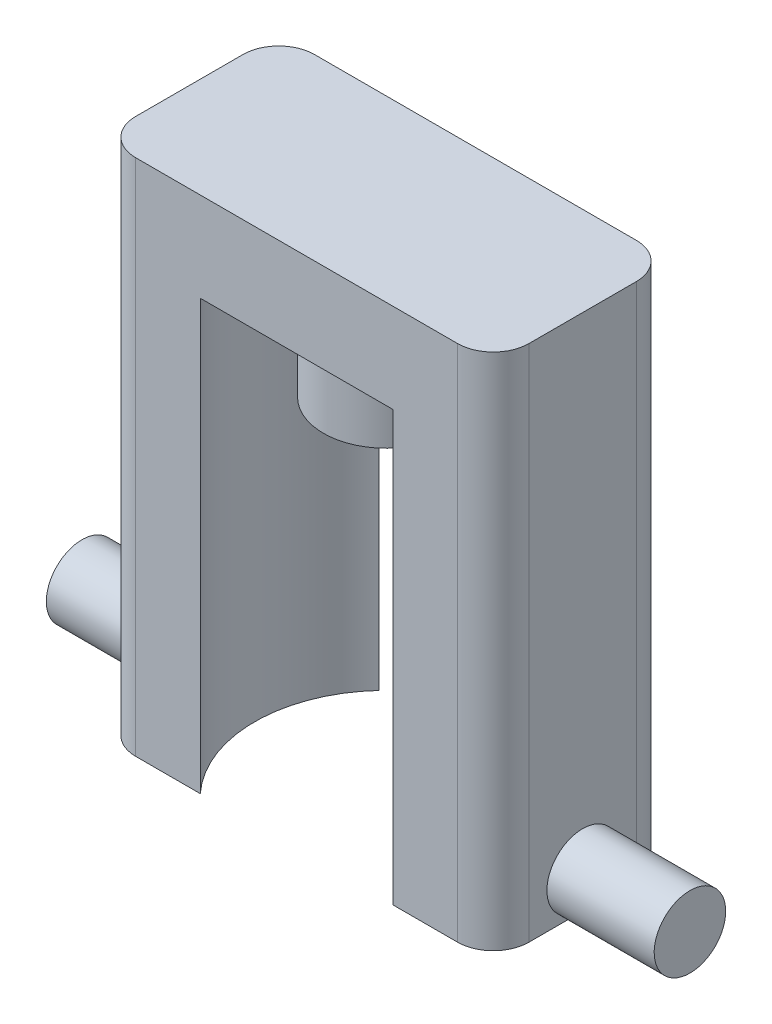
from build123d import *

# Parameters (mm, degrees)
SKETCH1_W           = 27.94
SKETCH1_H           = 12.7
BOSS_EXTRUDE1_DEPTH = 6.35
SKETCH2_R           = 4.445
BOSS_EXTRUDE2_DEPTH = 5.842
BOSS_EXTRUDE3_DEPTH = 30.48
SKETCH4_R           = 2.54
BOSS_EXTRUDE4_DEPTH = 7.62
SKETCH5_R           = 2.54
BOSS_EXTRUDE5_DEPTH = 7.62
FILLET1_R           = 2.54


with BuildPart() as part:
    # Sketch1 → Boss-Extrude1 (new body)
    with BuildSketch(Plane(origin=(0, 0, 0), x_dir=(1, 0, 0), z_dir=(0, 1, 0))):
        Rectangle(SKETCH1_W, SKETCH1_H)
    extrude(amount=BOSS_EXTRUDE1_DEPTH)

    # Sketch2 → Boss-Extrude2 (add)
    with BuildSketch(Plane.XZ):
        Circle(SKETCH2_R)
    extrude(amount=BOSS_EXTRUDE2_DEPTH)

    # Sketch3 → Boss-Extrude3 (add)
    with BuildSketch(Plane.XZ):
        with BuildLine():
            Line((-13.97, -6.35), (-13.97, 6.35))
            Line((-13.97, 6.35), (-6.841811913, 6.35))
            ThreePointArc((-6.841811913, 6.35), (-9.3345, 0), (-6.841811913, -6.35))
            Line((-6.841811913, -6.35), (-13.97, -6.35))
        make_face()
        with BuildLine():
            Line((6.841811913, -6.35), (13.97, -6.35))
            Line((13.97, -6.35), (13.97, 6.35))
            Line((13.97, 6.35), (6.841811913, 6.35))
            ThreePointArc((6.841811913, 6.35), (9.3345, 0), (6.841811913, -6.35))
        make_face()
    extrude(amount=BOSS_EXTRUDE3_DEPTH)

    # Sketch4 → Boss-Extrude4 (add)
    with BuildSketch(Plane.ZY.offset(13.97)):
        with Locations((0, -27.94)):
            Circle(SKETCH4_R)
    extrude(amount=BOSS_EXTRUDE4_DEPTH)

    # Sketch5 → Boss-Extrude5 (add)
    with BuildSketch(Plane(origin=(13.97, 0, 0), x_dir=(0, 0, -1), z_dir=(1, 0, 0))):
        with Locations((0, -27.94)):
            Circle(SKETCH5_R)
    extrude(amount=BOSS_EXTRUDE5_DEPTH)

    # Fillet1
    fillet1_edges = [part.edges().sort_by_distance(p)[0] for p in [
        (-13.97, -12.065, -6.35),
        (13.97, -12.065, -6.35),
        (13.97, -12.065, 6.35),
        (-13.97, -12.065, 6.35),
    ]]
    fillet(fillet1_edges, radius=FILLET1_R)


solid = part.part
